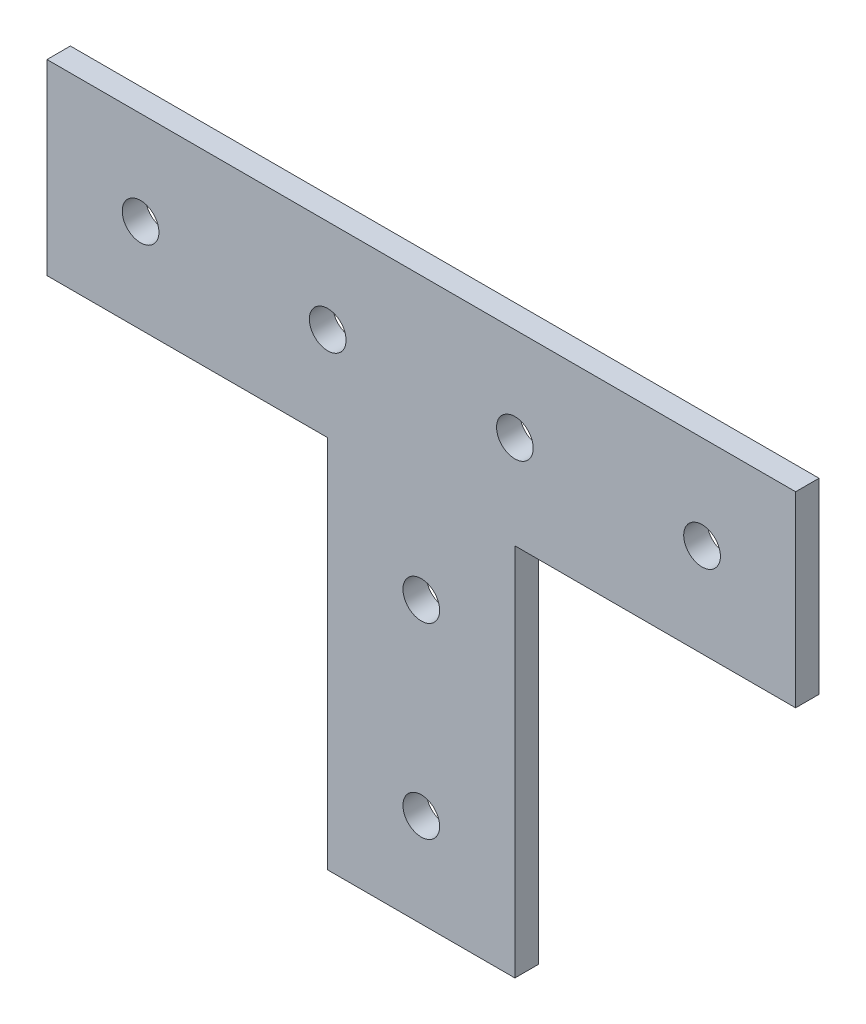
from build123d import *

# Parameters (mm, degrees)
SKETCH1_R           = 2.4892
BOSS_EXTRUDE1_DEPTH = 3.175


with BuildPart() as part:
    # Sketch1 → Boss-Extrude1 (new body)
    with BuildSketch(Plane.XY):
        Polygon((-50.8, 50.8), (-50.8, 25.4), (-12.7, 25.4), (-12.7, -25.4), (12.7, -25.4), (12.7, 25.4), (50.8, 25.4), (50.8, 50.8), align=None)
        with Locations((-38.1, 38.1)):
            Circle(SKETCH1_R, mode=Mode.SUBTRACT)
        with Locations((-12.7, 38.1)):
            Circle(SKETCH1_R, mode=Mode.SUBTRACT)
        with Locations((12.7, 38.1)):
            Circle(SKETCH1_R, mode=Mode.SUBTRACT)
        with Locations((38.1, 38.1)):
            Circle(SKETCH1_R, mode=Mode.SUBTRACT)
        with Locations((0, 12.7)):
            Circle(SKETCH1_R, mode=Mode.SUBTRACT)
        with Locations((0, -12.7)):
            Circle(SKETCH1_R, mode=Mode.SUBTRACT)
    extrude(amount=BOSS_EXTRUDE1_DEPTH)


solid = part.part
